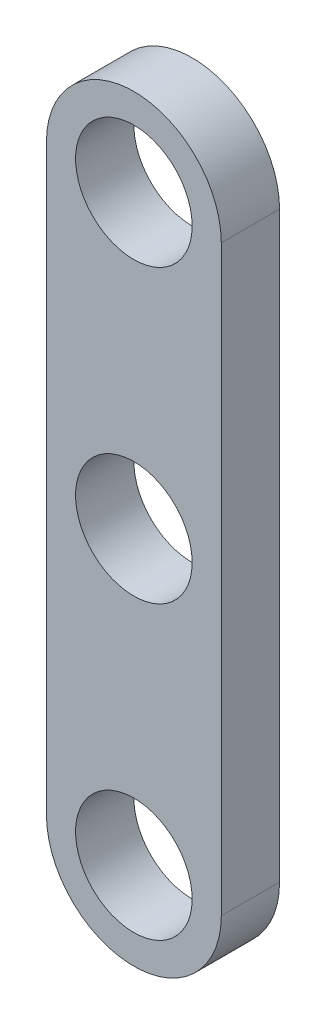
from build123d import *

# Parameters (mm, degrees)
SKETCH1_R           = 5
BOSS_EXTRUDE1_DEPTH = 2.5
SCALE1_SCALE        = 0.3


with BuildPart() as part:
    # Sketch1 → Boss-Extrude1 (new body, symmetric)
    with BuildSketch(Plane.XY):
        with BuildLine():
            Line((-7.5, 0), (-7.5, 50))
            ThreePointArc((-7.5, 50), (0, 57.5), (7.5, 50))
            Line((7.5, 50), (7.5, 0))
            ThreePointArc((7.5, 0), (0, -7.5), (-7.5, 0))
        make_face()
        with Locations((0, 50)):
            Circle(SKETCH1_R, mode=Mode.SUBTRACT)
        with Locations((0, 25)):
            Circle(SKETCH1_R, mode=Mode.SUBTRACT)
        Circle(SKETCH1_R, mode=Mode.SUBTRACT)
    extrude(amount=BOSS_EXTRUDE1_DEPTH, both=True)


with BuildPart() as part_1:
    # Scale1: scaled about (0, 25, 0)
    add(part.part.scale(SCALE1_SCALE).moved(Location((0, 17.5, 0))))


solid = part_1.part
